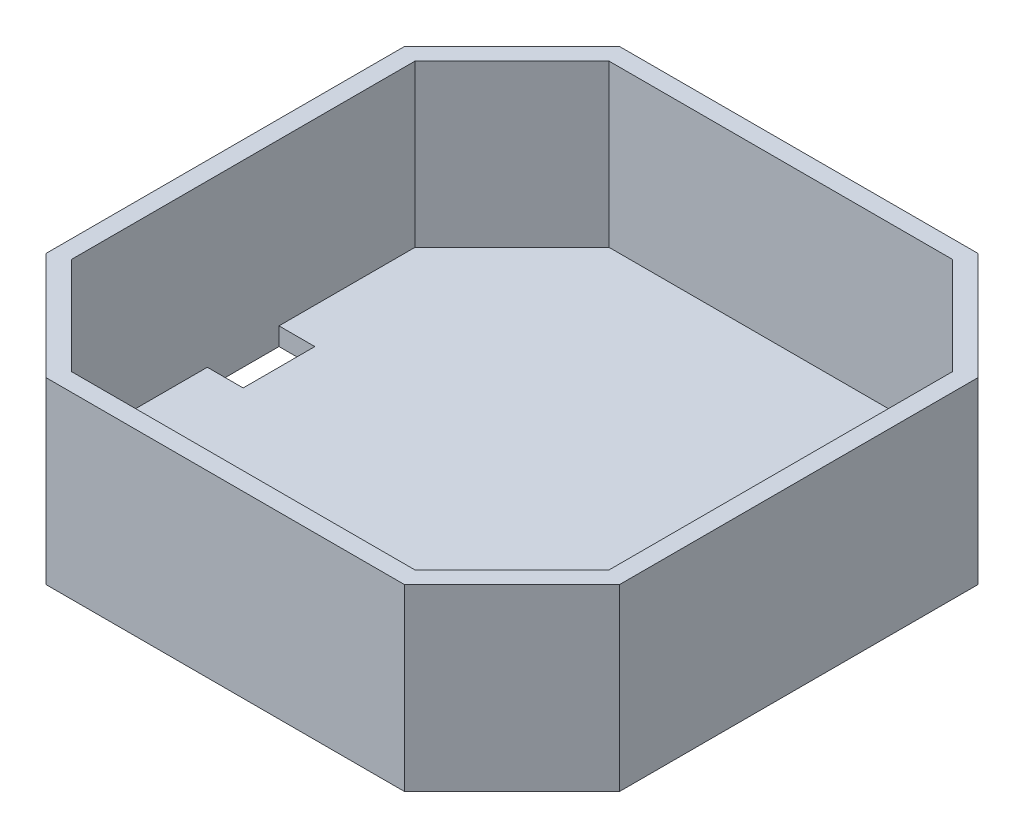
from build123d import *

# Parameters (mm, degrees)
BOSS_EXTRUDE1_DEPTH = 50
SHELL1_T            = -5
SKETCH5_W           = 10
SKETCH5_H           = 20
CUT_EXTRUDE1_DEPTH  = 5


with BuildPart() as part:
    # Sketch1 → Boss-Extrude1 (new body)
    with BuildSketch(Plane(origin=(0, 0, 0), x_dir=(1, 0, 0), z_dir=(0, 1, 0))):
        Polygon((-50, 80), (-80, 50), (-80, -50), (-50, -80), (50, -80), (80, -50), (80, 50), (50, 80), align=None)
    extrude(amount=BOSS_EXTRUDE1_DEPTH)

    # Shell1
    shell1_openings = [part.faces().sort_by_distance(p)[0] for p in [
        (0, 50, 0),
    ]]
    offset(amount=SHELL1_T, openings=shell1_openings, kind=Kind.INTERSECTION)

    # Sketch5 → Cut-Extrude1 (cut)
    with BuildSketch(Plane(origin=(0, 5, 0), x_dir=(1, 0, 0), z_dir=(0, 1, 0))):
        with Locations((-70, 0)):
            Rectangle(SKETCH5_W, SKETCH5_H)
    extrude(amount=-CUT_EXTRUDE1_DEPTH, mode=Mode.SUBTRACT)


solid = part.part
